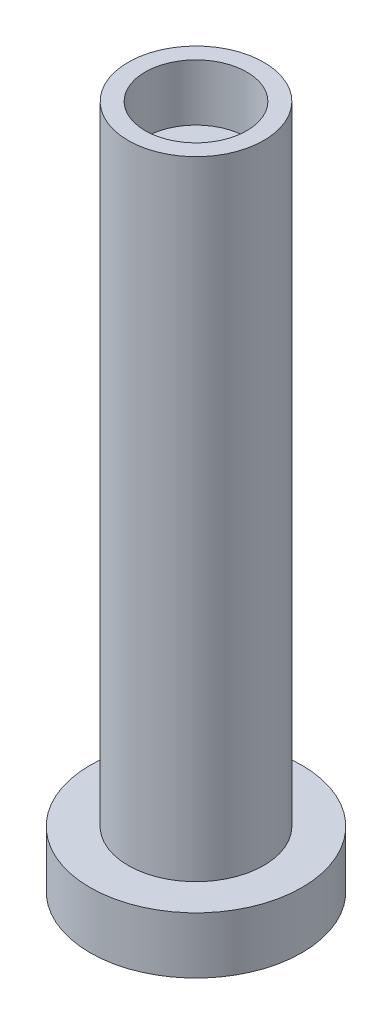
from build123d import *

# Parameters (mm, degrees)
SKETCH1_R           = 4.8
BOSS_EXTRUDE1_DEPTH = 44.45
SKETCH1_4_R         = 7.5
BOSS_EXTRUDE2_DEPTH = 4
SKETCH2_R           = 3.6
CUT_EXTRUDE1_DEPTH  = 4


with BuildPart() as part:
    # Sketch1 → Boss-Extrude1 (new body)
    with BuildSketch(Plane(origin=(0, 0, 0), x_dir=(1, 0, 0), z_dir=(0, 1, 0))):
        Circle(SKETCH1_R)
    extrude(amount=BOSS_EXTRUDE1_DEPTH)

    # Sketch1_4 → Boss-Extrude2 (add)
    with BuildSketch(Plane(origin=(0, 0, 0), x_dir=(1, 0, 0), z_dir=(0, 1, 0))):
        Circle(SKETCH1_4_R)
    extrude(amount=-BOSS_EXTRUDE2_DEPTH)

    # Sketch2 → Cut-Extrude1 (cut)
    with BuildSketch(Plane(origin=(0, 44.45, 0), x_dir=(1, 0, 0), z_dir=(0, 1, 0))):
        Circle(SKETCH2_R)
    extrude(amount=-CUT_EXTRUDE1_DEPTH, mode=Mode.SUBTRACT)


solid = part.part
